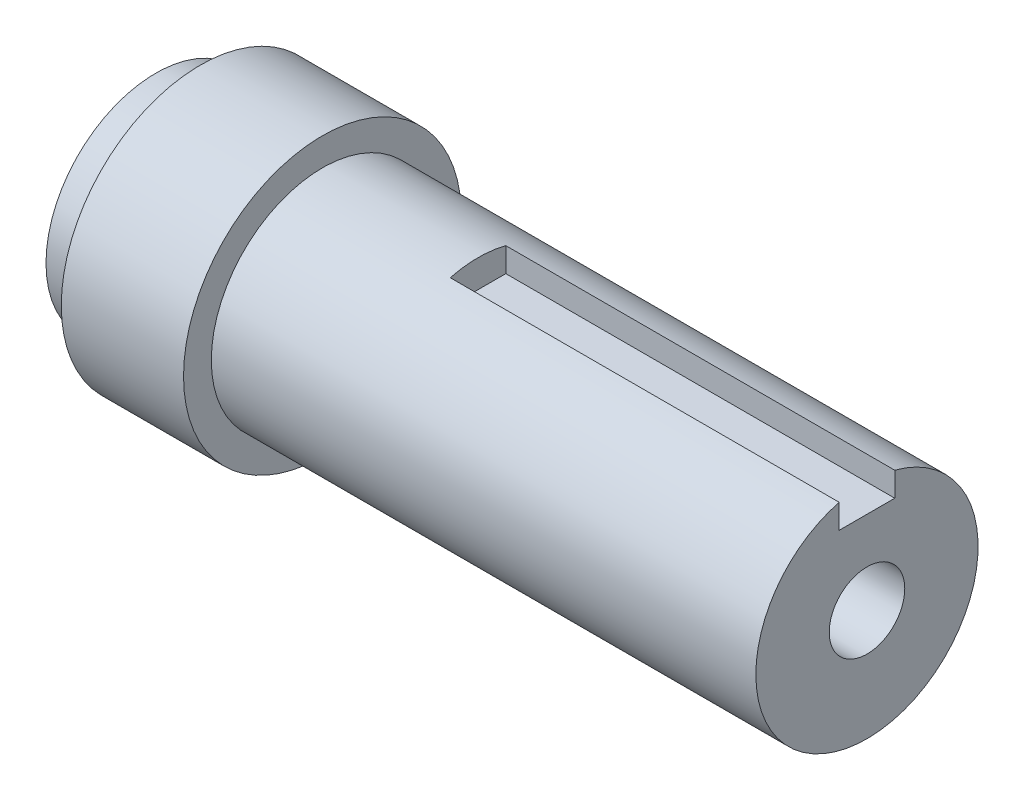
from build123d import *

# Parameters (mm, degrees)
CUT_EXTRUDE_START     = -35
SKETCH_2_W            = 5
SKETCH_2_H            = 5
CUT_EXTRUDE_1_DEPTH   = 35
HOLE_WIZARD_M81_D     = 6.8
HOLE_WIZARD_M81_DEPTH = 25
HOLE_WIZARD_M81_TIP   = 2.042926105


with BuildPart() as part:
    # Эскиз1 → Повернуть1 (revolve)
    with BuildSketch(Plane(origin=(0, 0, 0), x_dir=(1, 0, 0), z_dir=(0, 1, 0))):
        Polygon((0, 0), (0, 9.875), (4, 9.875), (4, 12.5), (15, 12.5), (15, 10), (64, 10), (64, 0), align=None)
    revolve(axis=Axis((-1000, 0, 0), (1, 0, 0)))

    # Эскиз2 → Вырез-Вытянуть1 (cut)
    with BuildSketch(Plane(origin=(64, 0, 0), x_dir=(0, 0, -1), z_dir=(1, 0, 0)).offset(CUT_EXTRUDE_START)):
        with Locations((0, 10)):
            Rectangle(SKETCH_2_W, SKETCH_2_H)
    extrude(amount=CUT_EXTRUDE_1_DEPTH, mode=Mode.SUBTRACT)

    # Отверстие обработанное метчиком M81
    with Locations(Plane(origin=(64, 0, 0), x_dir=(0, 0, -1), z_dir=(1, 0, 0))):
        with Locations((0, 0)):
            Hole(HOLE_WIZARD_M81_D / 2, depth=HOLE_WIZARD_M81_DEPTH)
            with Locations((0, 0, -(HOLE_WIZARD_M81_DEPTH + HOLE_WIZARD_M81_TIP / 2))):  # 118° drill point
                Cone(0, HOLE_WIZARD_M81_D / 2, HOLE_WIZARD_M81_TIP, mode=Mode.SUBTRACT)


solid = part.part
